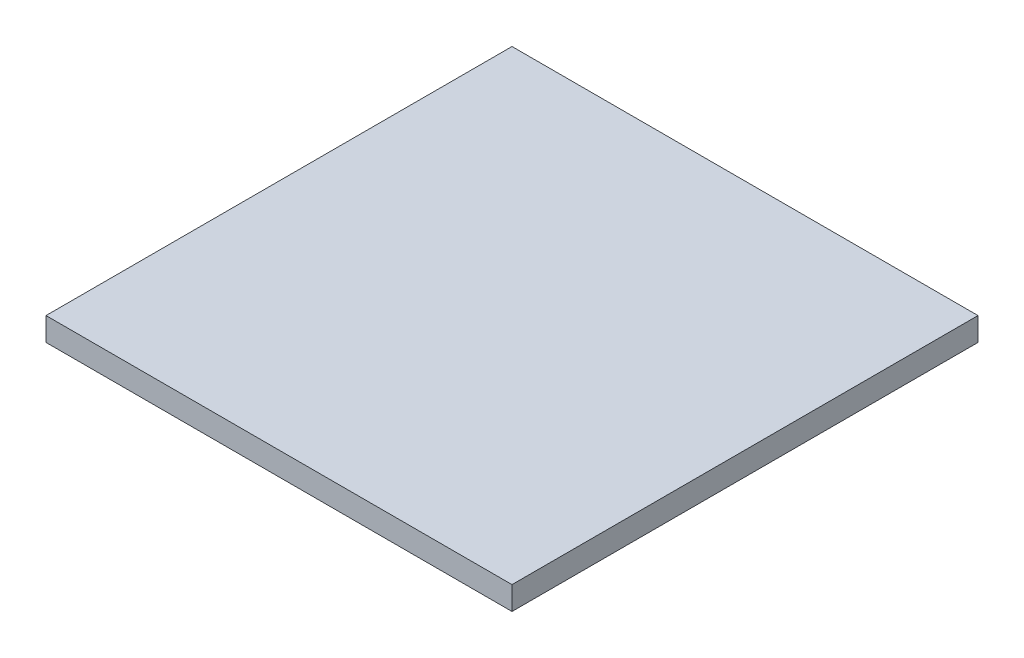
from build123d import *

# Parameters (mm, degrees)
SKETCH1_W           = 400
SKETCH1_H           = 400
BOSS_EXTRUDE1_DEPTH = 20


with BuildPart() as part:
    # Sketch1 → Boss-Extrude1 (new body)
    with BuildSketch(Plane(origin=(0, 0, 0), x_dir=(1, 0, 0), z_dir=(0, 1, 0))):
        Rectangle(SKETCH1_W, SKETCH1_H)
    extrude(amount=BOSS_EXTRUDE1_DEPTH)


solid = part.part
